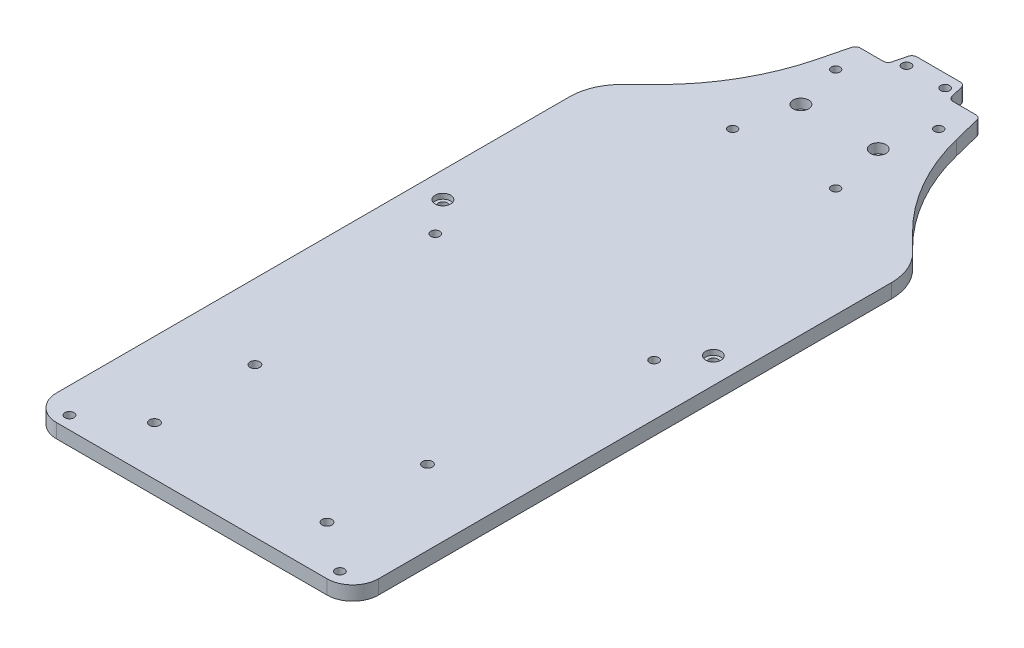
from build123d import *

# Parameters (mm, degrees)
DECK_BASE_DEPTH       = 5.5
BOLT_SLOT_REACH       = 7.5
SKETCH_3_R            = 1.75
SKETCH_14_R           = 3
BOLT_HEAD_DEPTH       = 2
FILLET_1_R            = 4
CUT_EXTRUDE_6_REACH   = 7.5
SKETCH_15_W           = 145
SKETCH_15_H           = 39
CUT_EXTRUDE_7_DEPTH   = 10
FILLET_2_R            = 2
SKETCH_17_OUTSIDE_W   = 211.856
SKETCH_17_OUTSIDE_H   = 356.856
SKETCH_17_OUTSIDE_W_2 = 125
SKETCH_17_OUTSIDE_H_2 = 290
CUT_EXTRUDE_8_DEPTH   = 10
FILLET_4_R            = 10
FILLET_5_R            = 20
LIDAR_SLOT_REACH      = 7.5
SKETCH_4_R            = 1.7
VESC_SLOT_REACH       = 7.5
SKETCH_6_R            = 1.9
NANO_SLOT_REACH       = 7.5
SKETCH_7_R            = 1.75
CUT_EXTRUDE_3_REACH   = 7.5
SKETCH_12_R           = 1.75
SKETCH_13_R           = 3
CUT_EXTRUDE_4_DEPTH   = 3.7


with BuildPart() as part:
    # 스케치1 → Deck base (new body)
    with BuildSketch(Plane(origin=(0, 0, 0), x_dir=(1, 0, 0), z_dir=(0, 1, 0))):
        with BuildLine():
            Line((-72.5, 0), (-72.5, -185))
            ThreePointArc((-72.5, -185), (-69.571067812, -192.071067812), (-62.5, -195))
            Line((-62.5, -195), (-49.962007487, -195))
            ThreePointArc((-49.962007487, -195), (-47.753248675, -195.514313374), (-45.998887542, -196.951446196))
            Line((-45.998887542, -196.951446196), (-19.001112458, -232.048553804))
            ThreePointArc((-19.001112458, -232.048553804), (-17.246751325, -233.485686626), (-15.037992513, -234))
            Line((-15.037992513, -234), (15.037992513, -234))
            ThreePointArc((15.037992513, -234), (17.246751325, -233.485686626), (19.001112458, -232.048553804))
            Line((19.001112458, -232.048553804), (45.998887542, -196.951446196))
            ThreePointArc((45.998887542, -196.951446196), (47.753248675, -195.514313374), (49.962007487, -195))
            Line((49.962007487, -195), (62.5, -195))
            ThreePointArc((62.5, -195), (69.571067812, -192.071067812), (72.5, -185))
            Line((72.5, -185), (72.5, 0))
            ThreePointArc((72.5, 0), (70.204904333, 11.508182998), (63.670781605, 21.255540601))
            Line((63.670781605, 21.255540601), (49.478231298, 35.391496426))
            ThreePointArc((49.478231298, 35.391496426), (35.536990456, 53.662264501), (27, 75))
            Line((27, 75), (22, 95))
            Line((22, 95), (-22, 95))
            Line((-22, 95), (-27, 75))
            ThreePointArc((-27, 75), (-35.536990456, 53.662264501), (-49.478231298, 35.391496426))
            Line((-49.478231298, 35.391496426), (-63.670781605, 21.255540601))
            ThreePointArc((-63.670781605, 21.255540601), (-70.204904333, 11.508182998), (-72.5, 0))
        make_face()
    extrude(amount=DECK_BASE_DEPTH)

    # 스케치3 → Bolt slot (cut, up to next)
    with BuildSketch(Plane(origin=(0, 5.5, 0), x_dir=(1, 0, 0), z_dir=(0, 1, 0)), mode=Mode.PRIVATE) as bolt_slot_sk1:
        with Locations((7.5, 90)):
            Circle(SKETCH_3_R)
    bolt_slot_tool1 = extrude(bolt_slot_sk1.sketch, amount=-BOLT_SLOT_REACH, mode=Mode.PRIVATE) & part.part
    add(bolt_slot_tool1.solids().sort_by_distance((7.5, 5.5, -90))[0], mode=Mode.SUBTRACT)
    # 스케치3 → Bolt slot (cut, up to next)
    with BuildSketch(Plane(origin=(0, 5.5, 0), x_dir=(1, 0, 0), z_dir=(0, 1, 0)), mode=Mode.PRIVATE) as bolt_slot_sk2:
        with Locations((-7.5, 90)):
            Circle(SKETCH_3_R)
    bolt_slot_tool2 = extrude(bolt_slot_sk2.sketch, amount=-BOLT_SLOT_REACH, mode=Mode.PRIVATE) & part.part
    add(bolt_slot_tool2.solids().sort_by_distance((-7.5, 5.5, -90))[0], mode=Mode.SUBTRACT)
    # 스케치3 → Bolt slot (cut, up to next)
    with BuildSketch(Plane(origin=(0, 5.5, 0), x_dir=(1, 0, 0), z_dir=(0, 1, 0)), mode=Mode.PRIVATE) as bolt_slot_sk3:
        with Locations((52.5, -45)):
            Circle(SKETCH_3_R)
    bolt_slot_tool3 = extrude(bolt_slot_sk3.sketch, amount=-BOLT_SLOT_REACH, mode=Mode.PRIVATE) & part.part
    add(bolt_slot_tool3.solids().sort_by_distance((52.5, 5.5, 45))[0], mode=Mode.SUBTRACT)
    # 스케치3 → Bolt slot (cut, up to next)
    with BuildSketch(Plane(origin=(0, 5.5, 0), x_dir=(1, 0, 0), z_dir=(0, 1, 0)), mode=Mode.PRIVATE) as bolt_slot_sk4:
        with Locations((52.5, -190)):
            Circle(SKETCH_3_R)
    bolt_slot_tool4 = extrude(bolt_slot_sk4.sketch, amount=-BOLT_SLOT_REACH, mode=Mode.PRIVATE) & part.part
    add(bolt_slot_tool4.solids().sort_by_distance((52.5, 5.5, 190))[0], mode=Mode.SUBTRACT)
    # 스케치3 → Bolt slot (cut, up to next)
    with BuildSketch(Plane(origin=(0, 5.5, 0), x_dir=(1, 0, 0), z_dir=(0, 1, 0)), mode=Mode.PRIVATE) as bolt_slot_sk5:
        with Locations((-52.5, -190)):
            Circle(SKETCH_3_R)
    bolt_slot_tool5 = extrude(bolt_slot_sk5.sketch, amount=-BOLT_SLOT_REACH, mode=Mode.PRIVATE) & part.part
    add(bolt_slot_tool5.solids().sort_by_distance((-52.5, 5.5, 190))[0], mode=Mode.SUBTRACT)
    # 스케치3 → Bolt slot (cut, up to next)
    with BuildSketch(Plane(origin=(0, 5.5, 0), x_dir=(1, 0, 0), z_dir=(0, 1, 0)), mode=Mode.PRIVATE) as bolt_slot_sk6:
        with Locations((-52.5, -45)):
            Circle(SKETCH_3_R)
    bolt_slot_tool6 = extrude(bolt_slot_sk6.sketch, amount=-BOLT_SLOT_REACH, mode=Mode.PRIVATE) & part.part
    add(bolt_slot_tool6.solids().sort_by_distance((-52.5, 5.5, 45))[0], mode=Mode.SUBTRACT)

    # 스케치14 → Bolt head (cut)
    with BuildSketch(Plane(origin=(0, 5.5, 0), x_dir=(1, 0, 0), z_dir=(0, 1, 0))):
        with Locations((-52.5, -45)):
            Circle(SKETCH_14_R)
        with Locations((52.5, -45)):
            Circle(SKETCH_14_R)
    extrude(amount=-BOLT_HEAD_DEPTH, mode=Mode.SUBTRACT)

    # 필렛1
    fillet_1_edges = [part.edges().sort_by_distance(p)[0] for p in [
        (22, 2.75, -95),
        (-22, 2.75, -95),
    ]]
    fillet(fillet_1_edges, radius=FILLET_1_R)

    # 스케치15 → 컷-돌출6 (cut, up to next)
    with BuildSketch(Plane(origin=(0, 5.5, 0), x_dir=(1, 0, 0), z_dir=(0, 1, 0)), mode=Mode.PRIVATE) as cut_extrude_6_sk1:
        with Locations((0, -214.5)):
            Rectangle(SKETCH_15_W, SKETCH_15_H)
    cut_extrude_6_tool1 = extrude(cut_extrude_6_sk1.sketch, amount=-CUT_EXTRUDE_6_REACH, mode=Mode.PRIVATE) & part.part
    add(cut_extrude_6_tool1.solids().sort_by_distance((0, 5.5, 214.5))[0], mode=Mode.SUBTRACT)

    # 스케치16 → 컷-돌출7 (cut)
    with BuildSketch(Plane(origin=(0, 5.5, 0), x_dir=(1, 0, 0), z_dir=(0, 1, 0))):
        Polygon((-9.999999999, 95), (10.000000001, 95), (12.000000001, 87), (24, 87), (24, 100), (-24, 100), (-24, 87), (-11.999999999, 87), align=None)
    extrude(amount=-CUT_EXTRUDE_7_DEPTH, mode=Mode.SUBTRACT)

    # 필렛2
    fillet_2_edges = [part.edges().sort_by_distance(p)[0] for p in [
        (-9.999999999, 2.75, -95),
        (-11.999999999, 2.75, -87),
        (-24, 2.75, -87),
        (24, 2.75, -87),
        (12.000000001, 2.75, -87),
        (10.000000001, 2.75, -95),
    ]]
    fillet(fillet_2_edges, radius=FILLET_2_R)

    # 스케치17 outside → 컷-돌출8 (cut)
    with BuildSketch(Plane(origin=(0, 5.5, 0), x_dir=(1, 0, 0), z_dir=(0, 1, 0))):
        with Locations((0, -50)):
            Rectangle(SKETCH_17_OUTSIDE_W, SKETCH_17_OUTSIDE_H)
        with Locations((0, -50)):
            Rectangle(SKETCH_17_OUTSIDE_W_2, SKETCH_17_OUTSIDE_H_2, mode=Mode.SUBTRACT)
    extrude(amount=-CUT_EXTRUDE_8_DEPTH, mode=Mode.SUBTRACT)

    # 필렛4
    fillet_4_edges = [part.edges().sort_by_distance(p)[0] for p in [
        (-62.5, 2.75, 195),
        (62.5, 2.75, 195),
    ]]
    fillet(fillet_4_edges, radius=FILLET_4_R)

    # 필렛5
    fillet_5_edges = [part.edges().sort_by_distance(p)[0] for p in [
        (-62.5, 2.75, -22.421653575),
        (62.5, 2.75, -22.421653575),
    ]]
    fillet(fillet_5_edges, radius=FILLET_5_R)

    # 스케치4 → Lidar slot (cut, up to next)
    with BuildSketch(Plane(origin=(0, 5.5, 0), x_dir=(1, 0, 0), z_dir=(0, 1, 0)), mode=Mode.PRIVATE) as lidar_slot_sk1:
        with Locations((-20, 75)):
            Circle(SKETCH_4_R)
    lidar_slot_tool1 = extrude(lidar_slot_sk1.sketch, amount=-LIDAR_SLOT_REACH, mode=Mode.PRIVATE) & part.part
    add(lidar_slot_tool1.solids().sort_by_distance((-20, 5.5, -75))[0], mode=Mode.SUBTRACT)
    # 스케치4 → Lidar slot (cut, up to next)
    with BuildSketch(Plane(origin=(0, 5.5, 0), x_dir=(1, 0, 0), z_dir=(0, 1, 0)), mode=Mode.PRIVATE) as lidar_slot_sk2:
        with Locations((-20, 35)):
            Circle(SKETCH_4_R)
    lidar_slot_tool2 = extrude(lidar_slot_sk2.sketch, amount=-LIDAR_SLOT_REACH, mode=Mode.PRIVATE) & part.part
    add(lidar_slot_tool2.solids().sort_by_distance((-20, 5.5, -35))[0], mode=Mode.SUBTRACT)
    # 스케치4 → Lidar slot (cut, up to next)
    with BuildSketch(Plane(origin=(0, 5.5, 0), x_dir=(1, 0, 0), z_dir=(0, 1, 0)), mode=Mode.PRIVATE) as lidar_slot_sk3:
        with Locations((20, 35)):
            Circle(SKETCH_4_R)
    lidar_slot_tool3 = extrude(lidar_slot_sk3.sketch, amount=-LIDAR_SLOT_REACH, mode=Mode.PRIVATE) & part.part
    add(lidar_slot_tool3.solids().sort_by_distance((20, 5.5, -35))[0], mode=Mode.SUBTRACT)
    # 스케치4 → Lidar slot (cut, up to next)
    with BuildSketch(Plane(origin=(0, 5.5, 0), x_dir=(1, 0, 0), z_dir=(0, 1, 0)), mode=Mode.PRIVATE) as lidar_slot_sk4:
        with Locations((20, 75)):
            Circle(SKETCH_4_R)
    lidar_slot_tool4 = extrude(lidar_slot_sk4.sketch, amount=-LIDAR_SLOT_REACH, mode=Mode.PRIVATE) & part.part
    add(lidar_slot_tool4.solids().sort_by_distance((20, 5.5, -75))[0], mode=Mode.SUBTRACT)

    # 스케치6 → Vesc slot (cut, up to next)
    with BuildSketch(Plane(origin=(0, 5.5, 0), x_dir=(1, 0, 0), z_dir=(0, 1, 0)), mode=Mode.PRIVATE) as vesc_slot_sk1:
        with Locations((33.5, -137)):
            Circle(SKETCH_6_R)
    vesc_slot_tool1 = extrude(vesc_slot_sk1.sketch, amount=-VESC_SLOT_REACH, mode=Mode.PRIVATE) & part.part
    add(vesc_slot_tool1.solids().sort_by_distance((33.5, 5.5, 137))[0], mode=Mode.SUBTRACT)
    # 스케치6 → Vesc slot (cut, up to next)
    with BuildSketch(Plane(origin=(0, 5.5, 0), x_dir=(1, 0, 0), z_dir=(0, 1, 0)), mode=Mode.PRIVATE) as vesc_slot_sk2:
        with Locations((33.5, -176)):
            Circle(SKETCH_6_R)
    vesc_slot_tool2 = extrude(vesc_slot_sk2.sketch, amount=-VESC_SLOT_REACH, mode=Mode.PRIVATE) & part.part
    add(vesc_slot_tool2.solids().sort_by_distance((33.5, 5.5, 176))[0], mode=Mode.SUBTRACT)
    # 스케치6 → Vesc slot (cut, up to next)
    with BuildSketch(Plane(origin=(0, 5.5, 0), x_dir=(1, 0, 0), z_dir=(0, 1, 0)), mode=Mode.PRIVATE) as vesc_slot_sk3:
        with Locations((-33.5, -176)):
            Circle(SKETCH_6_R)
    vesc_slot_tool3 = extrude(vesc_slot_sk3.sketch, amount=-VESC_SLOT_REACH, mode=Mode.PRIVATE) & part.part
    add(vesc_slot_tool3.solids().sort_by_distance((-33.5, 5.5, 176))[0], mode=Mode.SUBTRACT)
    # 스케치6 → Vesc slot (cut, up to next)
    with BuildSketch(Plane(origin=(0, 5.5, 0), x_dir=(1, 0, 0), z_dir=(0, 1, 0)), mode=Mode.PRIVATE) as vesc_slot_sk4:
        with Locations((-33.5, -137)):
            Circle(SKETCH_6_R)
    vesc_slot_tool4 = extrude(vesc_slot_sk4.sketch, amount=-VESC_SLOT_REACH, mode=Mode.PRIVATE) & part.part
    add(vesc_slot_tool4.solids().sort_by_distance((-33.5, 5.5, 137))[0], mode=Mode.SUBTRACT)

    # 스케치7 → Nano slot (cut, up to next)
    with BuildSketch(Plane(origin=(0, 5.5, 0), x_dir=(1, 0, 0), z_dir=(0, 1, 0)), mode=Mode.PRIVATE) as nano_slot_sk1:
        with Locations((-42.5, -58)):
            Circle(SKETCH_7_R)
    nano_slot_tool1 = extrude(nano_slot_sk1.sketch, amount=-NANO_SLOT_REACH, mode=Mode.PRIVATE) & part.part
    add(nano_slot_tool1.solids().sort_by_distance((-42.5, 5.5, 58))[0], mode=Mode.SUBTRACT)
    # 스케치7 → Nano slot (cut, up to next)
    with BuildSketch(Plane(origin=(0, 5.5, 0), x_dir=(1, 0, 0), z_dir=(0, 1, 0)), mode=Mode.PRIVATE) as nano_slot_sk2:
        with Locations((42.5, -58)):
            Circle(SKETCH_7_R)
    nano_slot_tool2 = extrude(nano_slot_sk2.sketch, amount=-NANO_SLOT_REACH, mode=Mode.PRIVATE) & part.part
    add(nano_slot_tool2.solids().sort_by_distance((42.5, 5.5, 58))[0], mode=Mode.SUBTRACT)

    # 스케치12 → 컷-돌출3 (cut, up to next)
    with BuildSketch(Plane(origin=(0, 5.5, 0), x_dir=(1, 0, 0), z_dir=(0, 1, 0)), mode=Mode.PRIVATE) as cut_extrude_3_sk1:
        with Locations((-15, 56.5)):
            Circle(SKETCH_12_R)
    cut_extrude_3_tool1 = extrude(cut_extrude_3_sk1.sketch, amount=-CUT_EXTRUDE_3_REACH, mode=Mode.PRIVATE) & part.part
    add(cut_extrude_3_tool1.solids().sort_by_distance((-15, 5.5, -56.5))[0], mode=Mode.SUBTRACT)
    # 스케치12 → 컷-돌출3 (cut, up to next)
    with BuildSketch(Plane(origin=(0, 5.5, 0), x_dir=(1, 0, 0), z_dir=(0, 1, 0)), mode=Mode.PRIVATE) as cut_extrude_3_sk2:
        with Locations((15, 56.5)):
            Circle(SKETCH_12_R)
    cut_extrude_3_tool2 = extrude(cut_extrude_3_sk2.sketch, amount=-CUT_EXTRUDE_3_REACH, mode=Mode.PRIVATE) & part.part
    add(cut_extrude_3_tool2.solids().sort_by_distance((15, 5.5, -56.5))[0], mode=Mode.SUBTRACT)

    # 스케치13 → 컷-돌출4 (cut)
    with BuildSketch(Plane(origin=(0, 5.5, 0), x_dir=(1, 0, 0), z_dir=(0, 1, 0))):
        with Locations((-15, 56.5)):
            Circle(SKETCH_13_R)
        with Locations((15, 56.5)):
            Circle(SKETCH_13_R)
    extrude(amount=-CUT_EXTRUDE_4_DEPTH, mode=Mode.SUBTRACT)


solid = part.part
